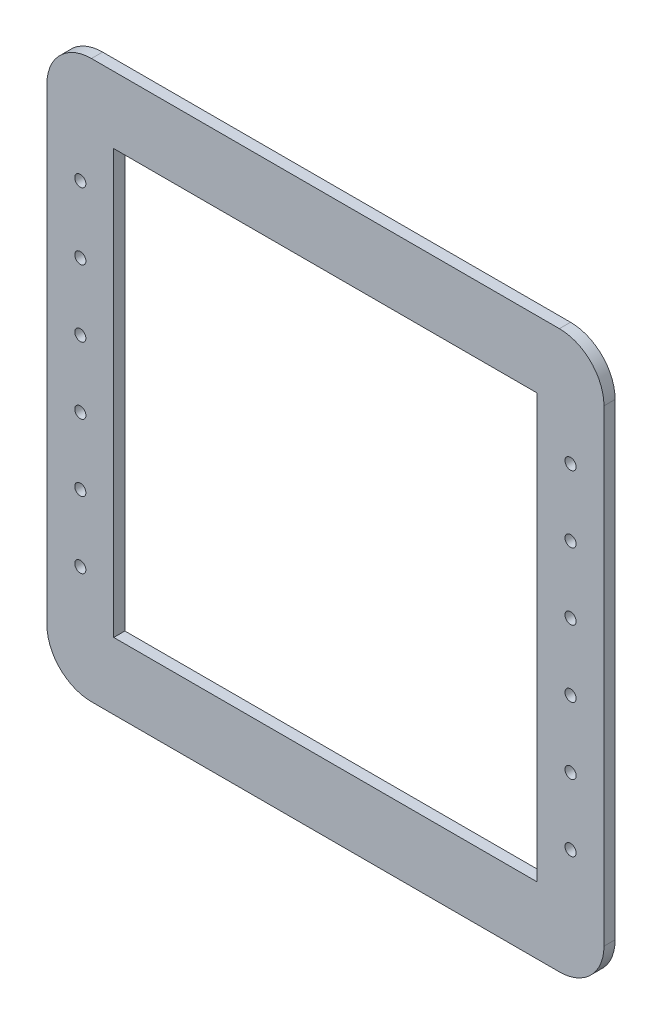
from build123d import *

# Parameters (mm, degrees)
SKETCH1_W           = 190
SKETCH1_H           = 190
BOSS_EXTRUDE1_DEPTH = 5
SKETCH2_R           = 2.5
CUT_EXTRUDE1_DEPTH  = 177.847391838
LPATTERN1_COUNT     = 6
LPATTERN1_PITCH     = 30


with BuildPart() as part:
    # Sketch1 → Boss-Extrude1 (new body)
    with BuildSketch(Plane.XY):
        with BuildLine():
            Line((-105, 125), (105, 125))
            ThreePointArc((105, 125), (119.142135624, 119.142135624), (125, 105))
            Line((125, 105), (125, -105))
            ThreePointArc((125, -105), (119.142135624, -119.142135624), (105, -125))
            Line((105, -125), (-105, -125))
            ThreePointArc((-105, -125), (-119.142135624, -119.142135624), (-125, -105))
            Line((-125, -105), (-125, 105))
            ThreePointArc((-125, 105), (-119.142135624, 119.142135624), (-105, 125))
        make_face()
        Rectangle(SKETCH1_W, SKETCH1_H, mode=Mode.SUBTRACT)
    extrude(amount=BOSS_EXTRUDE1_DEPTH)

    # Sketch2 → Cut-Extrude1 (cut, through all)
    with BuildSketch(Plane.XY.offset(5)):
        with Locations((-110, 75)):
            Circle(SKETCH2_R)
        with Locations((110, 75)):
            Circle(SKETCH2_R)
    cut_extrude1 = extrude(amount=-CUT_EXTRUDE1_DEPTH, mode=Mode.SUBTRACT)

    # LPattern1: Cut-Extrude1 ×6
    with Locations(*[(0, -i * LPATTERN1_PITCH, 0) for i in range(1, LPATTERN1_COUNT)]):
        add(cut_extrude1, mode=Mode.SUBTRACT)


solid = part.part
